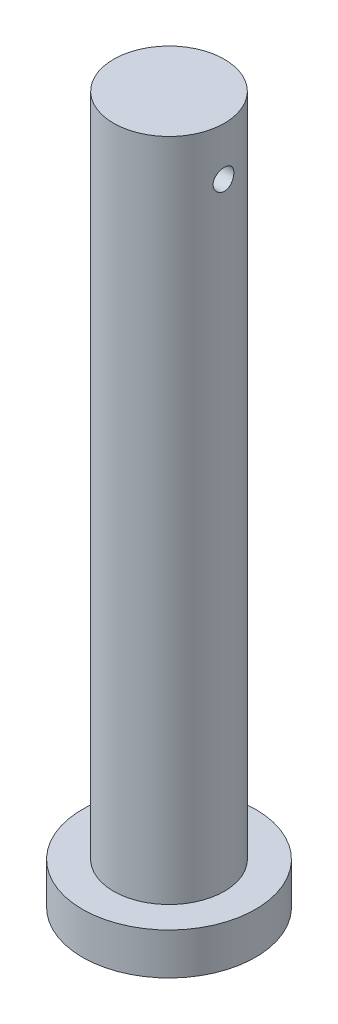
from build123d import *

# Parameters (mm, degrees)
SKETCH1_R               = 12.5
BOSS_EXTRUDE1_DEPTH     = 3
SKETCH2_R               = 8
BOSS_EXTRUDE2_DEPTH     = 96
SKETCH5_R               = 1.5
CUT_EXTRUDE1_DEPTH      = 13.5
CUT_EXTRUDE1_DEPTH_BACK = 13.5
SCALE1_SCALE            = 2


with BuildPart() as part:
    # Sketch1 → Boss-Extrude1 (new body, symmetric)
    with BuildSketch(Plane(origin=(0, 0, 0), x_dir=(1, 0, 0), z_dir=(0, 1, 0))):
        Circle(SKETCH1_R)
    extrude(amount=BOSS_EXTRUDE1_DEPTH, both=True)

    # Sketch2 → Boss-Extrude2 (add)
    with BuildSketch(Plane(origin=(0, 3, 0), x_dir=(1, 0, 0), z_dir=(0, 1, 0))):
        Circle(SKETCH2_R)
    extrude(amount=BOSS_EXTRUDE2_DEPTH)

    # Sketch5 → Cut-Extrude1 (cut, two sides)
    with BuildSketch(Plane(origin=(0, 0, 0), x_dir=(0, 0, -1), z_dir=(1, 0, 0))) as cut_extrude1_sk:
        with Locations((0, 92)):
            Circle(SKETCH5_R)
    extrude(amount=CUT_EXTRUDE1_DEPTH, mode=Mode.SUBTRACT)
    extrude(cut_extrude1_sk.sketch, amount=-CUT_EXTRUDE1_DEPTH_BACK, mode=Mode.SUBTRACT)


with BuildPart() as part_1:
    # Scale1: scaled about (-2.171e-06, 44.005415619, -5.482e-06)
    add(part.part.scale(SCALE1_SCALE).moved(Location((2.171e-06, -44.005415619, 5.482e-06))))


solid = part_1.part
